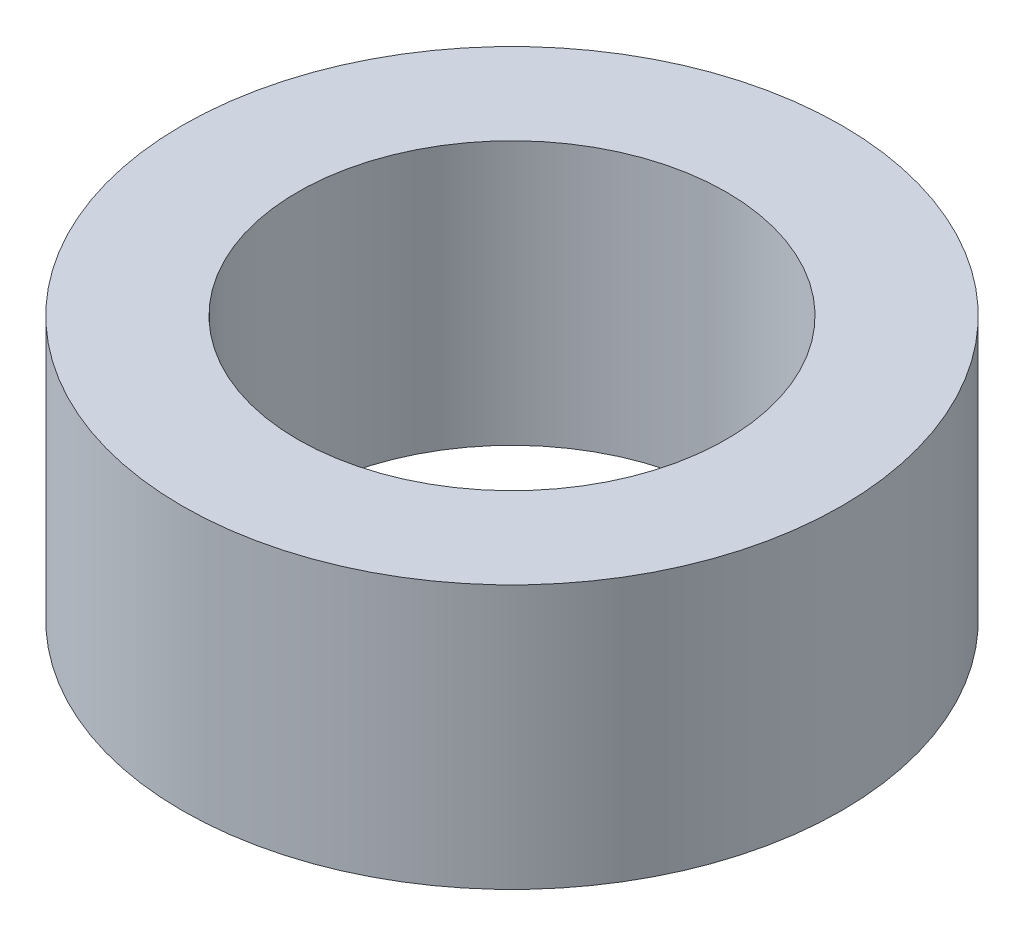
from build123d import *

# Parameters (mm, degrees)
SKETCH1_R           = 7.5
SKETCH1_R_2         = 4.875
BOSS_EXTRUDE1_DEPTH = 6


with BuildPart() as part:
    # Sketch1 → Boss-Extrude1 (new body)
    with BuildSketch(Plane(origin=(0, 0, 0), x_dir=(1, 0, 0), z_dir=(0, 1, 0))):
        Circle(SKETCH1_R)
        Circle(SKETCH1_R_2, mode=Mode.SUBTRACT)
    extrude(amount=BOSS_EXTRUDE1_DEPTH)


solid = part.part
